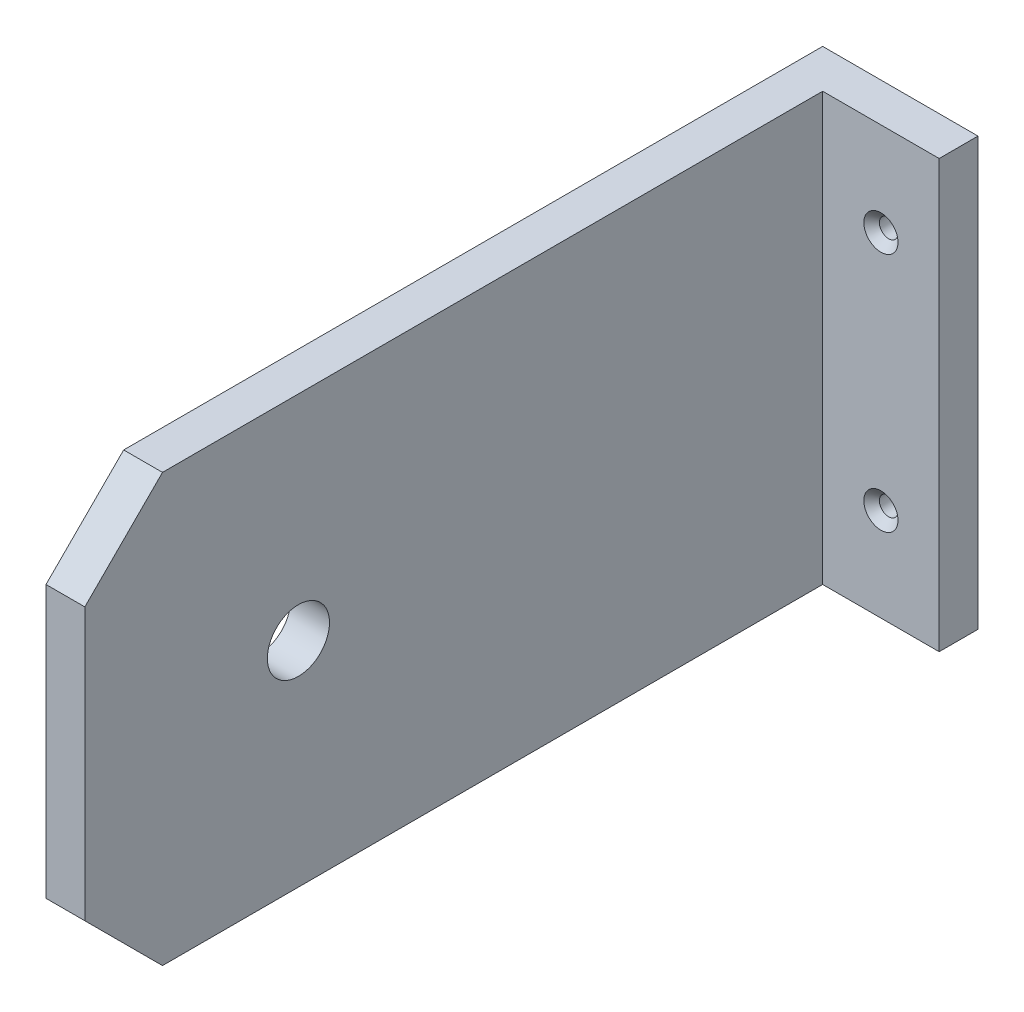
from build123d import *

# Parameters (mm, degrees)
SKETCH1_W                                       = 100
SKETCH1_H                                       = 55
BOSS_EXTRUDE1_DEPTH                             = 5
SKETCH2_W                                       = 5
SKETCH2_H                                       = 55
BOSS_EXTRUDE2_DEPTH                             = 15
CUT_EXTRUDE1_REACH                              = 22
CSK_FOR_M2_FLAT_HEAD_MACHINE_SCREW1_D           = 2.4
CSK_FOR_M2_FLAT_HEAD_MACHINE_SCREW1_CSINK_D     = 4.4
CSK_FOR_M2_FLAT_HEAD_MACHINE_SCREW1_CSINK_ANGLE = 90
CUT_EXTRUDE2_REACH                              = 22
SKETCH6_R                                       = 4


with BuildPart() as part:
    # Sketch1 → Boss-Extrude1 (new body)
    with BuildSketch(Plane(origin=(0, 0, 0), x_dir=(0, 0, -1), z_dir=(1, 0, 0))):
        Rectangle(SKETCH1_W, SKETCH1_H)
    extrude(amount=BOSS_EXTRUDE1_DEPTH)

    # Sketch2 → Boss-Extrude2 (add)
    with BuildSketch(Plane(origin=(5, 0, 0), x_dir=(0, 0, -1), z_dir=(1, 0, 0))):
        with Locations((47.5, 0)):
            Rectangle(SKETCH2_W, SKETCH2_H)
    extrude(amount=BOSS_EXTRUDE2_DEPTH)

    # Sketch3 → Cut-Extrude1 (cut, up to next)
    with BuildSketch(Plane.ZY, mode=Mode.PRIVATE) as cut_extrude1_sk1:
        Polygon((50, 27.5), (40, 27.5), (50, 17.5), align=None)
    cut_extrude1_tool1 = extrude(cut_extrude1_sk1.sketch, amount=-CUT_EXTRUDE1_REACH, mode=Mode.PRIVATE) & part.part
    add(cut_extrude1_tool1.solids().sort_by_distance((0, 24.166667, 46.666667))[0], mode=Mode.SUBTRACT)
    # Sketch3 → Cut-Extrude1 (cut, up to next)
    with BuildSketch(Plane.ZY, mode=Mode.PRIVATE) as cut_extrude1_sk2:
        Polygon((50, -27.5), (40, -27.5), (50, -17.5), align=None)
    cut_extrude1_tool2 = extrude(cut_extrude1_sk2.sketch, amount=-CUT_EXTRUDE1_REACH, mode=Mode.PRIVATE) & part.part
    add(cut_extrude1_tool2.solids().sort_by_distance((0, -24.166667, 46.666667))[0], mode=Mode.SUBTRACT)

    # CSK for M2 Flat Head Machine Screw1 (through all)
    with Locations(Plane.XY.offset(-45)):
        with Locations((12.5, 15.5), (12.5, -15.5)):
            CounterSinkHole(CSK_FOR_M2_FLAT_HEAD_MACHINE_SCREW1_D / 2, CSK_FOR_M2_FLAT_HEAD_MACHINE_SCREW1_CSINK_D / 2, counter_sink_angle=CSK_FOR_M2_FLAT_HEAD_MACHINE_SCREW1_CSINK_ANGLE)

    # Sketch6 → Cut-Extrude2 (cut, up to next)
    with BuildSketch(Plane.ZY, mode=Mode.PRIVATE) as cut_extrude2_sk1:
        with Locations((22.5, 0)):
            Circle(SKETCH6_R)
    cut_extrude2_tool1 = extrude(cut_extrude2_sk1.sketch, amount=-CUT_EXTRUDE2_REACH, mode=Mode.PRIVATE) & part.part
    add(cut_extrude2_tool1.solids().sort_by_distance((0, 0, 22.5))[0], mode=Mode.SUBTRACT)


solid = part.part
